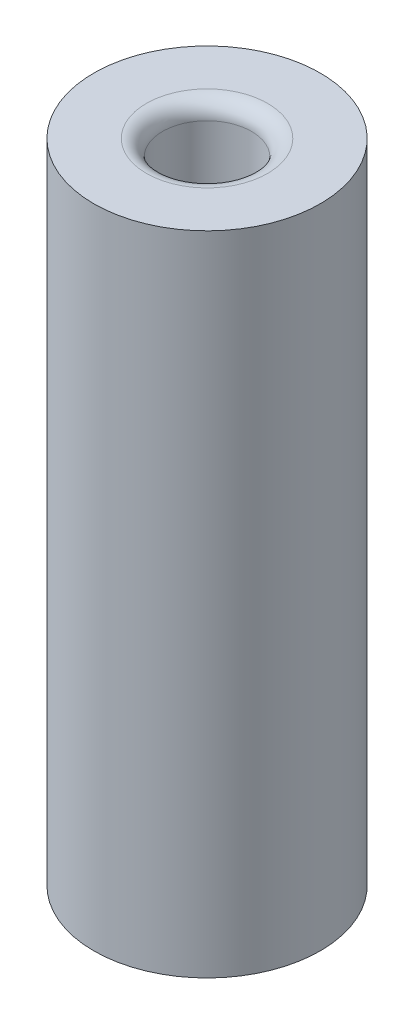
from build123d import *

# Parameters (mm, degrees)
SKETCH1_R           = 0.3556
SKETCH1_R_2         = 0.1397
BOSS_EXTRUDE1_DEPTH = 2.159
SKETCH2_R           = 0.4064
CUT_EXTRUDE1_DEPTH  = 0.127
FILLET1_R           = 0.0508


with BuildPart() as part:
    # Sketch1 → Boss-Extrude1 (new body)
    with BuildSketch(Plane(origin=(0, 0, 0), x_dir=(1, 0, 0), z_dir=(0, 1, 0))):
        Circle(SKETCH1_R)
        Circle(SKETCH1_R_2, mode=Mode.SUBTRACT)
    extrude(amount=BOSS_EXTRUDE1_DEPTH)

    # Sketch2 → Cut-Extrude1 (cut)
    with BuildSketch(Plane(origin=(0, 2.159, 0), x_dir=(1, 0, 0), z_dir=(0, 1, 0))):
        Circle(SKETCH2_R)
    extrude(amount=-CUT_EXTRUDE1_DEPTH, mode=Mode.SUBTRACT)

    # Fillet1
    fillet1_edges = [part.edges().sort_by_distance(p)[0] for p in [
        (-0.1397, 2.032, 0),
    ]]
    fillet(fillet1_edges, radius=FILLET1_R)


solid = part.part
